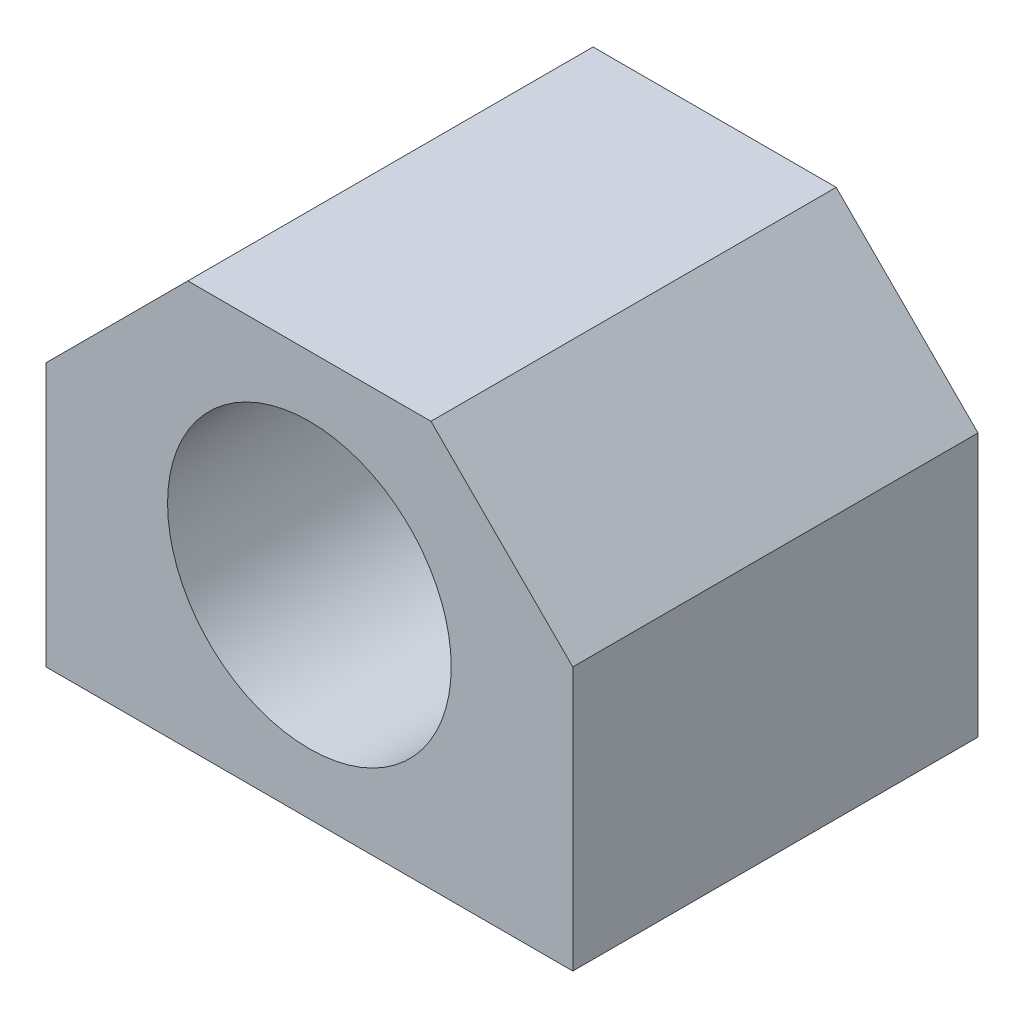
from build123d import *

# Parameters (mm, degrees)
AUFSATZ_LINEAR_AUSTRAGEN1_DEPTH = 40
SKIZZE2_R                       = 14
SCHNITT_LINEAR_AUSTRAGEN1_DEPTH = 40
SKIZZE3_R                       = 2.1
SCHNITT_LINEAR_AUSTRAGEN2_DEPTH = 15


with BuildPart() as part:
    # Skizze1 → Aufsatz-Linear austragen1 (new body)
    with BuildSketch(Plane.XY):
        Polygon((-26, 0), (26, 0), (26, 26), (12, 40), (-12, 40), (-26, 26), align=None)
    extrude(amount=AUFSATZ_LINEAR_AUSTRAGEN1_DEPTH)

    # Skizze2 → Schnitt-Linear austragen1 (cut)
    with BuildSketch(Plane.XY.offset(40)):
        with Locations((0, 20)):
            Circle(SKIZZE2_R)
    extrude(amount=-SCHNITT_LINEAR_AUSTRAGEN1_DEPTH, mode=Mode.SUBTRACT)

    # Skizze3 → Schnitt-Linear austragen2 (cut)
    with BuildSketch(Plane.XZ):
        with Locations((-20, 32)):
            Circle(SKIZZE3_R)
        with Locations((20, 32)):
            Circle(SKIZZE3_R)
        with Locations((-20, 8)):
            Circle(SKIZZE3_R)
        with Locations((20, 8)):
            Circle(SKIZZE3_R)
    extrude(amount=-SCHNITT_LINEAR_AUSTRAGEN2_DEPTH, mode=Mode.SUBTRACT)


solid = part.part
